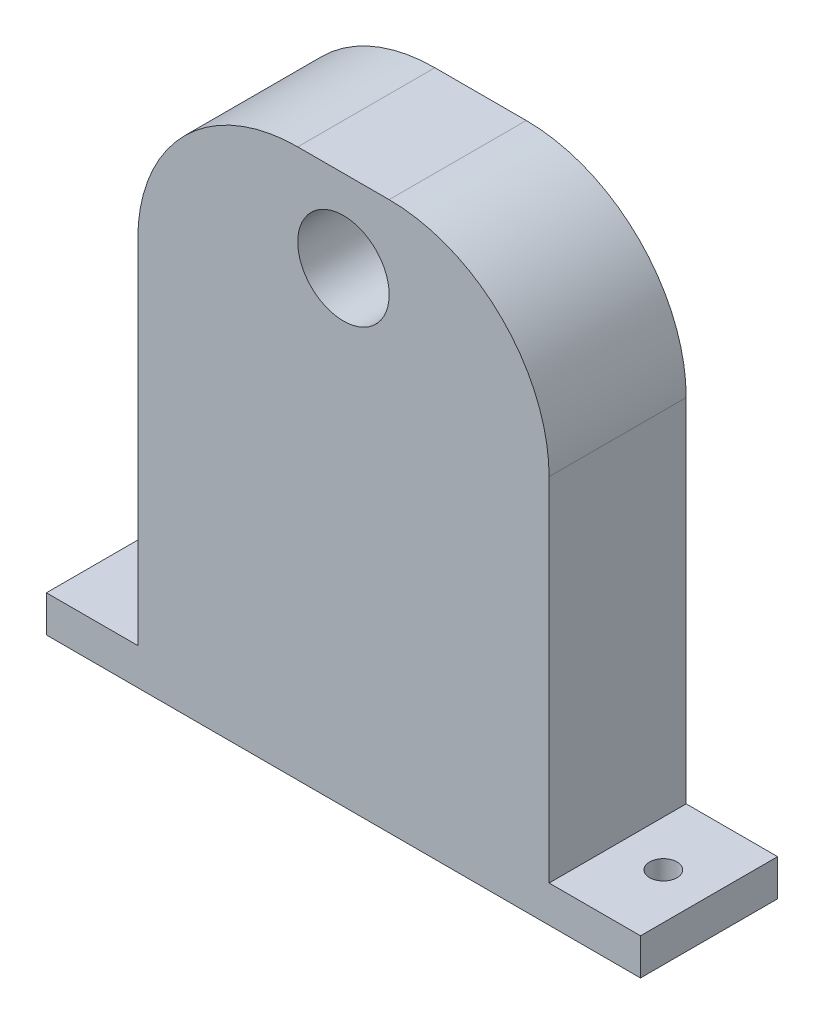
from build123d import *

# Parameters (mm, degrees)
SKETCH1_W           = 65
SKETCH1_H           = 15
BOSS_EXTRUDE1_DEPTH = 4
SKETCH2_W           = 45
SKETCH2_H           = 15
BOSS_EXTRUDE2_DEPTH = 56
SKETCH3_R           = 5
CUT_EXTRUDE1_DEPTH  = 10
CUT_EXTRUDE4_REACH  = 6
SKETCH5_R           = 1.5
CUT_EXTRUDE5_REACH  = 17


with BuildPart() as part:
    # Sketch1 → Boss-Extrude1 (new body)
    with BuildSketch(Plane(origin=(0, 0, 0), x_dir=(1, 0, 0), z_dir=(0, 1, 0))):
        Rectangle(SKETCH1_W, SKETCH1_H)
    extrude(amount=BOSS_EXTRUDE1_DEPTH)

    # Sketch2 → Boss-Extrude2 (add)
    with BuildSketch(Plane(origin=(0, 4, 0), x_dir=(1, 0, 0), z_dir=(0, 1, 0))):
        Rectangle(SKETCH2_W, SKETCH2_H)
    extrude(amount=BOSS_EXTRUDE2_DEPTH)

    # Sketch3 → Cut-Extrude1 (cut)
    with BuildSketch(Plane.XY.offset(7.5)):
        with Locations((0, 51)):
            Circle(SKETCH3_R)
    extrude(amount=-CUT_EXTRUDE1_DEPTH, mode=Mode.SUBTRACT)

    # Sketch5 → Cut-Extrude4 (cut, up to next)
    with BuildSketch(Plane(origin=(0, 4, 0), x_dir=(1, 0, 0), z_dir=(0, 1, 0)), mode=Mode.PRIVATE) as cut_extrude4_sk1:
        with Locations((-27.5, 0)):
            Circle(SKETCH5_R)
    cut_extrude4_tool1 = extrude(cut_extrude4_sk1.sketch, amount=-CUT_EXTRUDE4_REACH, mode=Mode.PRIVATE) & part.part
    add(cut_extrude4_tool1.solids().sort_by_distance((-27.5, 4, 0))[0], mode=Mode.SUBTRACT)
    # Sketch5 → Cut-Extrude4 (cut, up to next)
    with BuildSketch(Plane(origin=(0, 4, 0), x_dir=(1, 0, 0), z_dir=(0, 1, 0)), mode=Mode.PRIVATE) as cut_extrude4_sk2:
        with Locations((27.5, 0)):
            Circle(SKETCH5_R)
    cut_extrude4_tool2 = extrude(cut_extrude4_sk2.sketch, amount=-CUT_EXTRUDE4_REACH, mode=Mode.PRIVATE) & part.part
    add(cut_extrude4_tool2.solids().sort_by_distance((27.5, 4, 0))[0], mode=Mode.SUBTRACT)

    # Sketch6 → Cut-Extrude5 (cut, up to next)
    with BuildSketch(Plane.XY.offset(7.5), mode=Mode.PRIVATE) as cut_extrude5_sk1:
        with BuildLine():
            Line((5, 60), (22.5, 60))
            Line((22.5, 60), (22.5, 42.5))
            ThreePointArc((22.5, 42.5), (17.374368671, 54.874368671), (5, 60))
        make_face()
    cut_extrude5_tool1 = extrude(cut_extrude5_sk1.sketch, amount=-CUT_EXTRUDE5_REACH, mode=Mode.PRIVATE) & part.part
    add(cut_extrude5_tool1.solids().sort_by_distance((18.591061, 56.091061, 7.5))[0], mode=Mode.SUBTRACT)
    # Sketch6 → Cut-Extrude5 (cut, up to next)
    with BuildSketch(Plane.XY.offset(7.5), mode=Mode.PRIVATE) as cut_extrude5_sk2:
        with BuildLine():
            Line((-22.5, 42.5), (-22.5, 60))
            Line((-22.5, 60), (-5, 60))
            ThreePointArc((-5, 60), (-17.374368671, 54.874368671), (-22.5, 42.5))
        make_face()
    cut_extrude5_tool2 = extrude(cut_extrude5_sk2.sketch, amount=-CUT_EXTRUDE5_REACH, mode=Mode.PRIVATE) & part.part
    add(cut_extrude5_tool2.solids().sort_by_distance((-18.591061, 56.091061, 7.5))[0], mode=Mode.SUBTRACT)


solid = part.part
